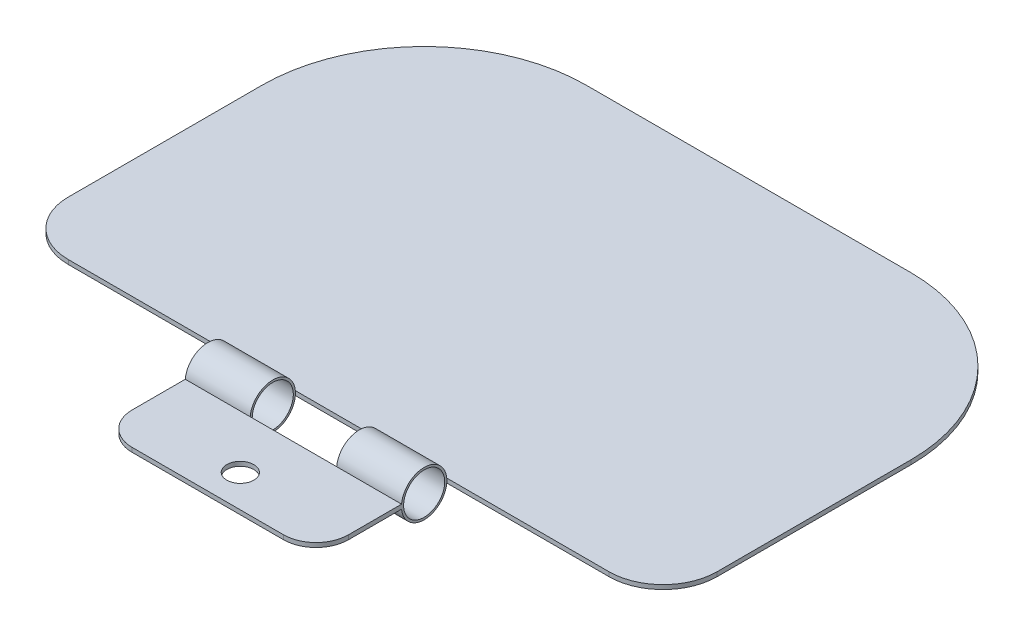
from build123d import *

# Parameters (mm, degrees)
SKETCH_1_R               = 1.9
EXTRUDE_1_DEPTH          = 20
SKETCH_2_W               = 37.909545504
SKETCH_2_H               = 0.4
EXTRUDE_2_DEPTH          = 20
EXTRUDE_2_DEPTH_BACK     = 40
FILLET_1_R               = 15
FILLET_2_R               = 5
FILLET_3_R               = 3
CUT_EXTRUDE_1_DEPTH      = 20
SKETCH_4_W               = 8
SKETCH_4_H               = 4.180908992
CUT_EXTRUDE_2_DEPTH      = 2.9
CUT_EXTRUDE_2_DEPTH_BACK = 3.3


with BuildPart() as part:
    # 草图1 → 凸台-拉伸1 (new body)
    with BuildSketch(Plane(origin=(0, 0, 0), x_dir=(0, 0, -1), z_dir=(1, 0, 0))):
        with BuildLine():
            Line((-10, -0.2), (-2.090454496, -0.2))
            ThreePointArc((-2.090454496, -0.2), (0, -2.1), (2.090454496, -0.2))
            Line((2.090454496, -0.2), (40, -0.2))
            Line((40, -0.2), (40, 0.2))
            Line((40, 0.2), (2.090454496, 0.2))
            ThreePointArc((2.090454496, 0.2), (0, 2.1), (-2.090454496, 0.2))
            Line((-2.090454496, 0.2), (-10, 0.2))
            Line((-10, 0.2), (-10, -0.2))
        make_face()
        Circle(SKETCH_1_R, mode=Mode.SUBTRACT)
    extrude(amount=EXTRUDE_1_DEPTH)

    # 草图2 → 凸台-拉伸2 (add, two sides)
    with BuildSketch(Plane(origin=(20, 0, 0), x_dir=(0, 0, -1), z_dir=(1, 0, 0))) as extrude_2_sk:
        with Locations((21.045227248, 0)):
            Rectangle(SKETCH_2_W, SKETCH_2_H)
    extrude(amount=EXTRUDE_2_DEPTH)
    extrude(extrude_2_sk.sketch, amount=-EXTRUDE_2_DEPTH_BACK)

    # 圆角1
    fillet_1_edges = [part.edges().sort_by_distance(p)[0] for p in [
        (-20, 0, -40),
        (40, 0, -40),
    ]]
    fillet(fillet_1_edges, radius=FILLET_1_R)

    # 圆角2
    fillet_2_edges = [part.edges().sort_by_distance(p)[0] for p in [
        (-20, 0, -2.090454496),
        (40, 0, -2.090454496),
    ]]
    fillet(fillet_2_edges, radius=FILLET_2_R)

    # 圆角3
    fillet_3_edges = [part.edges().sort_by_distance(p)[0] for p in [
        (0, 0, 10),
        (20, 0, 10),
    ]]
    fillet(fillet_3_edges, radius=FILLET_3_R)

    # 草图3 → 切除-拉伸1 (cut)
    with BuildSketch(Plane(origin=(0, 0.2, 0), x_dir=(1, 0, 0), z_dir=(0, 1, 0))):
        with BuildLine():
            ThreePointArc((11.25, -7), (10.883883476, -6.116116524), (10, -5.75))
            Line((10, -5.75), (10, -8.25))
            ThreePointArc((10, -8.25), (10.883883476, -7.883883476), (11.25, -7))
        make_face()
        with BuildLine():
            Line((10, -8.25), (10, -5.75))
            ThreePointArc((10, -5.75), (8.75, -7), (10, -8.25))
        make_face()
    extrude(amount=-CUT_EXTRUDE_1_DEPTH, mode=Mode.SUBTRACT)

    # 草图4 → 切除-拉伸2 (cut, two sides)
    with BuildSketch(Plane(origin=(0, 0.2, 0), x_dir=(1, 0, 0), z_dir=(0, 1, 0))) as cut_extrude_2_sk:
        with Locations((10, 0)):
            Rectangle(SKETCH_4_W, SKETCH_4_H)
    extrude(amount=CUT_EXTRUDE_2_DEPTH, mode=Mode.SUBTRACT)
    extrude(cut_extrude_2_sk.sketch, amount=-CUT_EXTRUDE_2_DEPTH_BACK, mode=Mode.SUBTRACT)


solid = part.part
